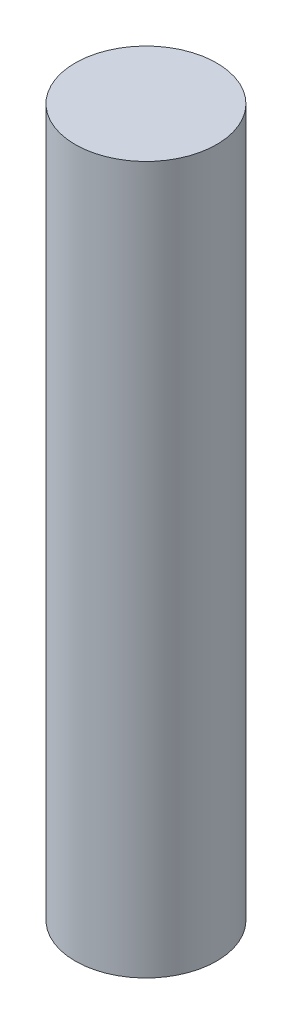
from build123d import *

# Parameters (mm, degrees)
SKETCH1_R           = 10
BOSS_EXTRUDE1_DEPTH = 100


with BuildPart() as part:
    # Sketch1 → Boss-Extrude1 (new body)
    with BuildSketch(Plane(origin=(0, 0, 0), x_dir=(1, 0, 0), z_dir=(0, 1, 0))):
        Circle(SKETCH1_R)
    extrude(amount=BOSS_EXTRUDE1_DEPTH)


solid = part.part
